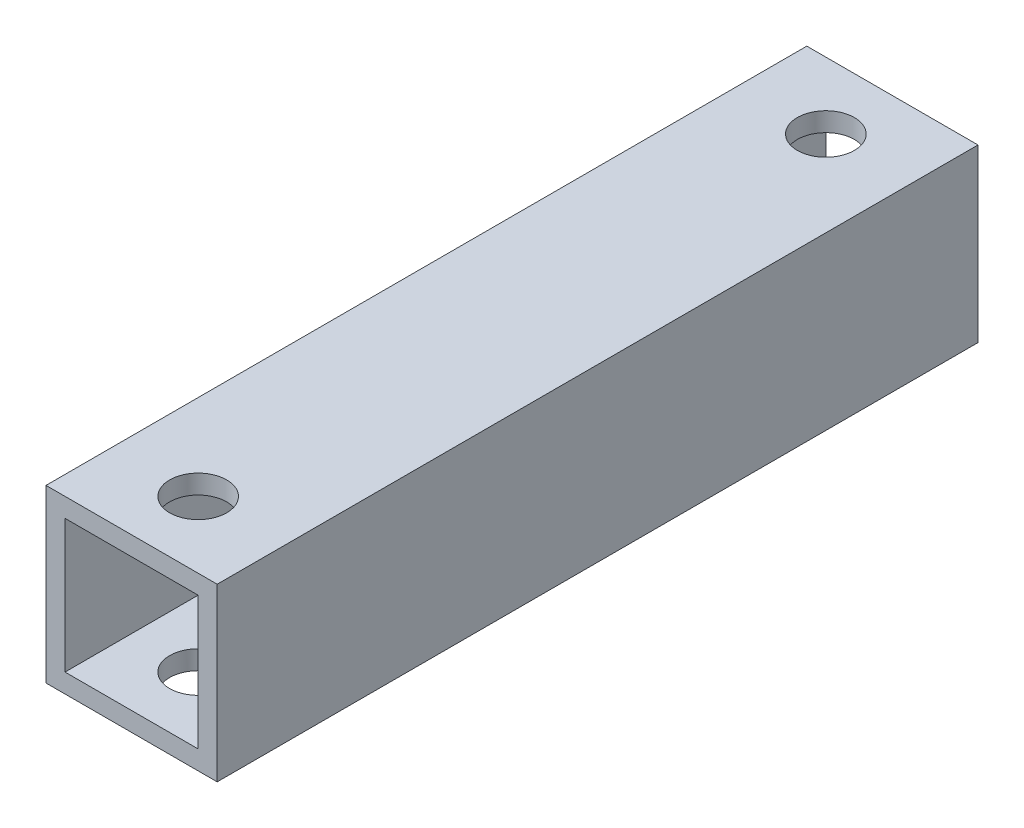
from build123d import *

# Parameters (mm, degrees)
SKETCH_1_W          = 9
SKETCH_1_H          = 9
EXTRUDE_1_DEPTH     = 40
SKETCH_2_W          = 7
SKETCH_2_H          = 7
CUT_EXTRUDE_1_DEPTH = 40
SKETCH_3_R          = 1.5
CUT_EXTRUDE_2_DEPTH = 38


with BuildPart() as part:
    # ｽｹｯﾁ1 → ﾎﾞｽ - 押し出し1 (new body)
    with BuildSketch(Plane.XY):
        Rectangle(SKETCH_1_W, SKETCH_1_H)
    extrude(amount=EXTRUDE_1_DEPTH)

    # ｽｹｯﾁ2 → ｶｯﾄ - 押し出し1 (cut)
    with BuildSketch(Plane.XY.offset(40)):
        Rectangle(SKETCH_2_W, SKETCH_2_H)
    extrude(amount=-CUT_EXTRUDE_1_DEPTH, mode=Mode.SUBTRACT)

    # ｽｹｯﾁ3 → ｶｯﾄ - 押し出し2 (cut)
    with BuildSketch(Plane(origin=(0, 4.5, 0), x_dir=(1, 0, 0), z_dir=(0, 1, 0))):
        with Locations((0, -3.5)):
            Circle(SKETCH_3_R)
        with Locations((0, -36.5)):
            Circle(SKETCH_3_R)
    extrude(amount=-CUT_EXTRUDE_2_DEPTH, mode=Mode.SUBTRACT)


solid = part.part
